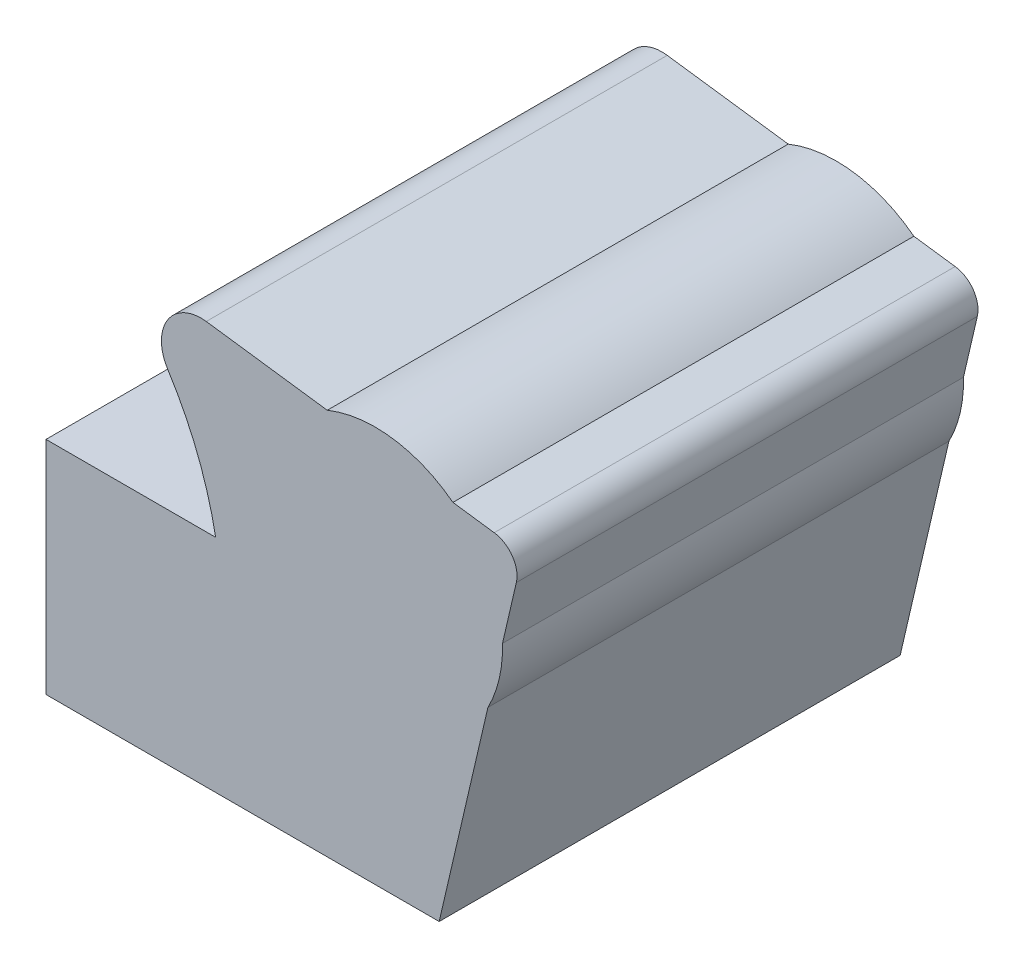
from build123d import *

# Parameters (mm, degrees)
SKETCH_1_R                     = 27.60110162
EXTRUDE_1_DEPTH                = 50
SPLIT_BODIES_1_SURFACE_1_BACK  = 231.64
SPLIT_BODIES_1_SURFACE_1_DEPTH = 463.28
SPLIT_BODIES_1_SURFACE_2_BACK  = 231.64
SPLIT_BODIES_1_SURFACE_2_DEPTH = 463.28


with BuildPart() as part:
    # 草图1 → 凸台-拉伸1 (new, symmetric)
    with BuildSketch(Plane.XY):
        with Locations((126.841, 106.3205)):
            Circle(SKETCH_1_R)
        with BuildLine():
            Line((0, 29.556947787), (33.841128496, 29.556947787))
            Line((33.841128496, 29.556947787), (55.404404979, 43.133825573))
            Line((55.404404979, 43.133825573), (55.404404979, 95.897124924))
            Line((55.404404979, 95.897124924), (92.202864513, 95.897124924))
            ThreePointArc((92.202864513, 95.897124924), (88.266951773, 109.605982584), (81.786119565, 122.311217777))
            ThreePointArc((81.786119565, 122.311217777), (81.790702408, 131.54578908), (90.169806602, 135.427533672))
            Line((90.169806602, 135.427533672), (152.632483554, 126.981321854))
            ThreePointArc((152.632483554, 126.981321854), (156.573746893, 124.561834969), (157.437634447, 120.018579331))
            Line((157.437634447, 120.018579331), (140.698476255, 47.962391292))
            Line((140.698476255, 47.962391292), (125.156200351, 47.962391292))
            Line((125.156200351, 47.962391292), (116.770080258, 26.493923855))
            Line((116.770080258, 26.493923855), (133.542320443, 26.493923855))
            Line((133.542320443, 26.493923855), (144.001, 0))
            Line((144.001, 0), (0, 0))
            Line((0, 0), (0, 29.556947787))
        make_face()
    extrude(amount=EXTRUDE_1_DEPTH, both=True)


with BuildPart() as body_2:
    # Split Bodies 1: the piece behind the surface
    add(part.part)
    # Split Bodies 1 surface: a surface, the sketch's curves swept straight by 463.28 mm
    with BuildLine(Plane.XY.offset(50).offset(-SPLIT_BODIES_1_SURFACE_1_BACK), mode=Mode.PRIVATE) as split_bodies_1_surface_1_path:
        Line((125.156200351, 47.962391292), (37.921543342, 47.962391292))
    split_bodies_1_surface_1 = Shell.extrude(split_bodies_1_surface_1_path.wire(), (0 * SPLIT_BODIES_1_SURFACE_1_DEPTH, 0 * SPLIT_BODIES_1_SURFACE_1_DEPTH, 1 * SPLIT_BODIES_1_SURFACE_1_DEPTH))
    split(bisect_by=split_bodies_1_surface_1, keep=Keep.BOTTOM)


with BuildPart() as part_1:
    add(part.part)

    # Split Bodies 1: split by a surface, the side it looks to stays
    # Split Bodies 1 surface: a surface, the sketch's curves swept straight by 463.28 mm
    with BuildLine(Plane.XY.offset(50).offset(-SPLIT_BODIES_1_SURFACE_2_BACK), mode=Mode.PRIVATE) as split_bodies_1_surface_2_path:
        Line((125.156200351, 47.962391292), (37.921543342, 47.962391292))
    split_bodies_1_surface_2 = Shell.extrude(split_bodies_1_surface_2_path.wire(), (0 * SPLIT_BODIES_1_SURFACE_2_DEPTH, 0 * SPLIT_BODIES_1_SURFACE_2_DEPTH, 1 * SPLIT_BODIES_1_SURFACE_2_DEPTH))
    split(bisect_by=split_bodies_1_surface_2, keep=Keep.TOP)


solid = body_2.part
